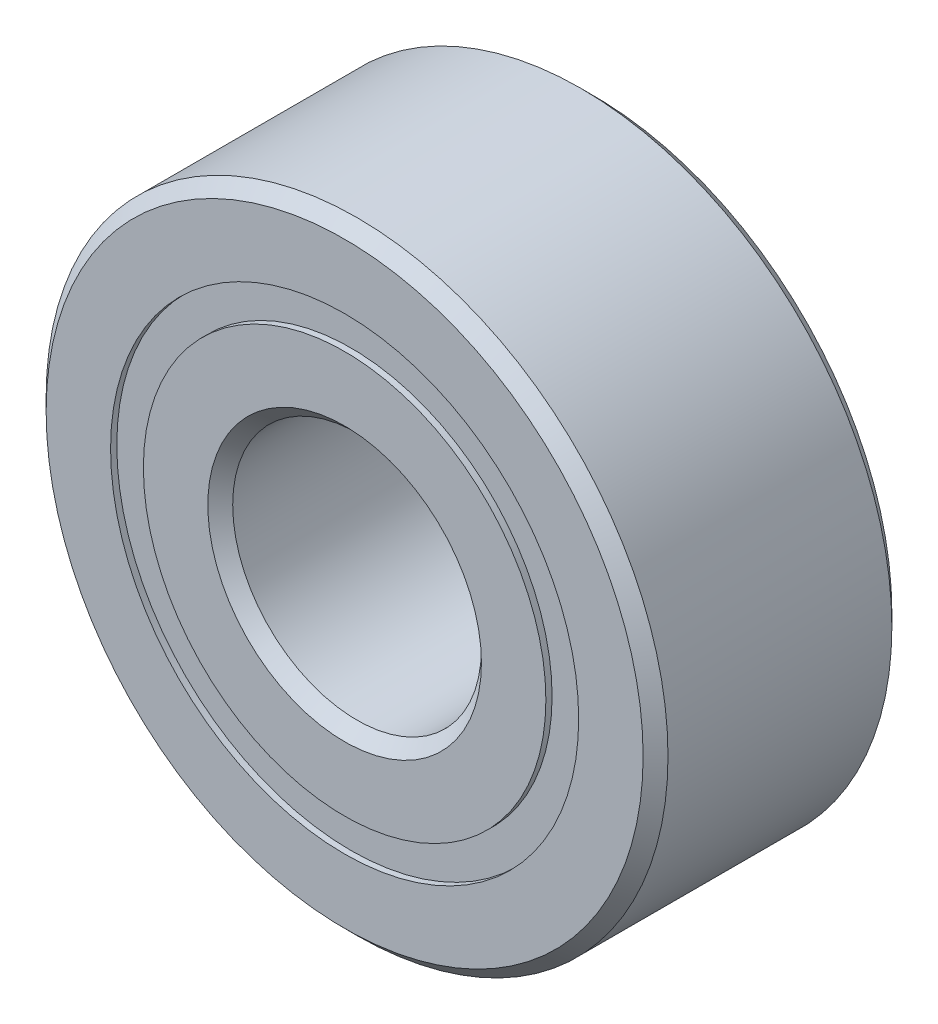
from build123d import *

# Parameters (mm, degrees)
CIRPATTERN1_COUNT = 12
SKETCH5_W         = 0.972810551
SKETCH5_H         = 0.527472528


with BuildPart() as part:
    # Sketch1 → Revolve1 (revolve)
    with BuildSketch(Plane(origin=(0, 0, 0), x_dir=(0, 0, -1), z_dir=(1, 0, 0))):
        with BuildLine():
            Line((1.8, 5), (-1.8, 5))
            Line((-1.8, 5), (-2, 4.8))
            Line((-2, 4.8), (-2, 3.763736264))
            Line((-2, 3.763736264), (-0.888888889, 3.763736264))
            ThreePointArc((-0.888888889, 3.763736264), (0, 4.427189449), (0.888888889, 3.763736264))
            Line((0.888888889, 3.763736264), (2, 3.763736264))
            Line((2, 3.763736264), (2, 4.8))
            Line((2, 4.8), (1.8, 5))
        make_face()
    revolve(axis=Axis((0, 0, 2), (0, 0, -1)))


with BuildPart() as body_2:
    # Sketch3 → Revolve3 (revolve)
    with BuildSketch(Plane(origin=(0, 0, 0), x_dir=(0, 0, -1), z_dir=(1, 0, 0))):
        with BuildLine():
            Line((-2, 3.236263736), (-0.888888889, 3.236263736))
            ThreePointArc((-0.888888889, 3.236263736), (0, 2.572810551), (0.888888889, 3.236263736))
            Line((0.888888889, 3.236263736), (2, 3.236263736))
            Line((2, 3.236263736), (2, 2.2))
            Line((2, 2.2), (1.8, 2))
            Line((1.8, 2), (-1.8, 2))
            Line((-1.8, 2), (-2, 2.2))
            Line((-2, 2.2), (-2, 3.236263736))
        make_face()
    revolve(axis=Axis((0, 0, 2), (0, 0, -1)))


with BuildPart() as body_3:
    # Sketch4 → Revolve4 (revolve)
    with BuildSketch(Plane(origin=(0, 0, 0), x_dir=(0, 0, -1), z_dir=(1, 0, 0))):
        with BuildLine():
            Line((-0.927189449, 3.5), (0.927189449, 3.5))
            ThreePointArc((0.927189449, 3.5), (0, 4.427189449), (-0.927189449, 3.5))
        make_face()
    revolve(axis=Axis((0, 3.5, 0.927189449), (0, 0, -1)))


with BuildPart() as cirpattern1_1:
    # CirPattern1: pattern copy
    add(body_3.part.rotate(Axis((0, 0, -2), (0, 0, 1)), 1 * 360 / CIRPATTERN1_COUNT))


with BuildPart() as cirpattern1_2:
    # CirPattern1: pattern copy
    add(body_3.part.rotate(Axis((0, 0, -2), (0, 0, 1)), 2 * 360 / CIRPATTERN1_COUNT))


with BuildPart() as cirpattern1_3:
    # CirPattern1: pattern copy
    add(body_3.part.rotate(Axis((0, 0, -2), (0, 0, 1)), 3 * 360 / CIRPATTERN1_COUNT))


with BuildPart() as cirpattern1_4:
    # CirPattern1: pattern copy
    add(body_3.part.rotate(Axis((0, 0, -2), (0, 0, 1)), 4 * 360 / CIRPATTERN1_COUNT))


with BuildPart() as cirpattern1_5:
    # CirPattern1: pattern copy
    add(body_3.part.rotate(Axis((0, 0, -2), (0, 0, 1)), 5 * 360 / CIRPATTERN1_COUNT))


with BuildPart() as cirpattern1_6:
    # CirPattern1: pattern copy
    add(body_3.part.rotate(Axis((0, 0, -2), (0, 0, 1)), 6 * 360 / CIRPATTERN1_COUNT))


with BuildPart() as cirpattern1_7:
    # CirPattern1: pattern copy
    add(body_3.part.rotate(Axis((0, 0, -2), (0, 0, 1)), 7 * 360 / CIRPATTERN1_COUNT))


with BuildPart() as cirpattern1_8:
    # CirPattern1: pattern copy
    add(body_3.part.rotate(Axis((0, 0, -2), (0, 0, 1)), 8 * 360 / CIRPATTERN1_COUNT))


with BuildPart() as cirpattern1_9:
    # CirPattern1: pattern copy
    add(body_3.part.rotate(Axis((0, 0, -2), (0, 0, 1)), 9 * 360 / CIRPATTERN1_COUNT))


with BuildPart() as cirpattern1_10:
    # CirPattern1: pattern copy
    add(body_3.part.rotate(Axis((0, 0, -2), (0, 0, 1)), 10 * 360 / CIRPATTERN1_COUNT))


with BuildPart() as cirpattern1_11:
    # CirPattern1: pattern copy
    add(body_3.part.rotate(Axis((0, 0, -2), (0, 0, 1)), 11 * 360 / CIRPATTERN1_COUNT))


with BuildPart() as body_15:
    # Sketch5 → Revolve5 (revolve)
    with BuildSketch(Plane(origin=(0, 0, 0), x_dir=(0, 0, -1), z_dir=(1, 0, 0))):
        with Locations((-1.413594725, 3.5)):
            Rectangle(SKETCH5_W, SKETCH5_H)
        with Locations((1.413594725, 3.5)):
            Rectangle(SKETCH5_W, SKETCH5_H)
    revolve(axis=Axis((0, 0, 2), (0, 0, -1)))


solid = Compound([part.part, body_2.part, body_3.part, cirpattern1_1.part, cirpattern1_2.part, cirpattern1_3.part, cirpattern1_4.part, cirpattern1_5.part, cirpattern1_6.part, cirpattern1_7.part, cirpattern1_8.part, cirpattern1_9.part, cirpattern1_10.part, cirpattern1_11.part, body_15.part])
